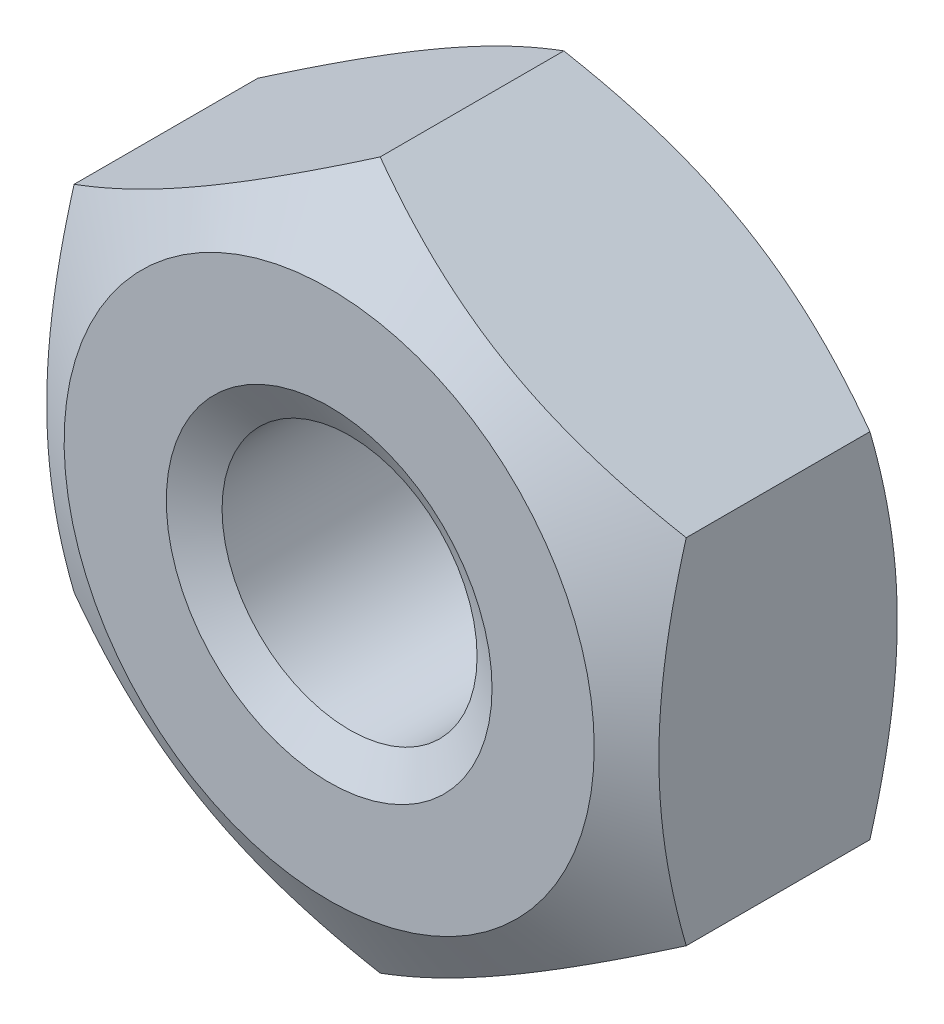
from build123d import *

# Parameters (mm, degrees)
BOSS_EXTRUDE1_DEPTH = 1.4
M1_7_TAPPED_HOLE1_D = 1.25
CHAMFER1_SIZE       = 0.1
CHAMFER1_SIZE2      = 0.173205081


with BuildPart() as part:
    # Sketch1 → Boss-Extrude1 (new body)
    with BuildSketch(Plane.XY):
        Polygon((0, 1.732050808), (-1.5, 0.866025404), (-1.5, -0.866025404), (0, -1.732050808), (1.5, -0.866025404), (1.5, 0.866025404), align=None)
    extrude(amount=-BOSS_EXTRUDE1_DEPTH)

    # Sketch2 → Cut-Revolve1 (revolve, cut)
    with BuildSketch(Plane(origin=(0, 0, 0), x_dir=(0, 0, -1), z_dir=(1, 0, 0))):
        Polygon((0, -1.299038106), (0.25, -1.732050808), (0, -1.732050808), align=None)
        Polygon((1.4, -1.732050808), (1.4, -1.299038106), (1.15, -1.732050808), align=None)
    revolve(axis=Axis((0, 0, 0), (0, 0, -1)), mode=Mode.SUBTRACT)

    # M1.7 Tapped Hole1 (through all)
    with Locations(Plane.XY):
        with Locations((0, 0)):
            Hole(M1_7_TAPPED_HOLE1_D / 2)

    # Chamfer1
    chamfer1_edges = [part.edges().sort_by_distance(p)[0] for p in [
        (0.625, 0, 0),
    ]]
    chamfer1_side = [part.faces().sort_by_distance(p)[0] for p in [
        (0.625, 0, -0.7),
    ]]
    chamfer(chamfer1_edges, length=CHAMFER1_SIZE, length2=CHAMFER1_SIZE2, reference=chamfer1_side[0])


solid = part.part
